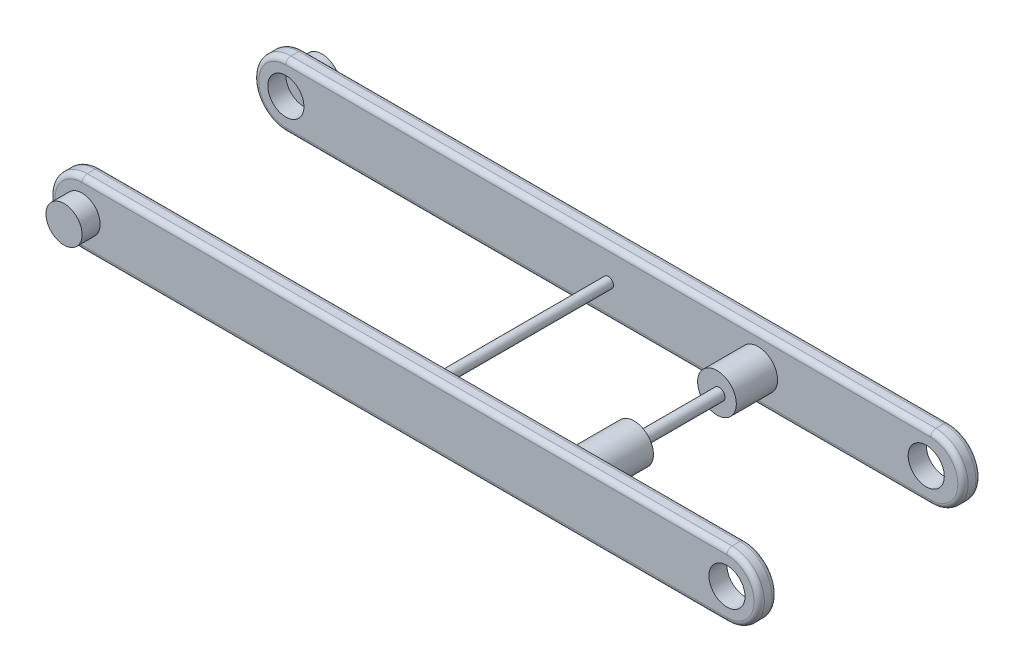
from build123d import *

# Parameters (mm, degrees)
BOSS_EXTRUDE1_DEPTH = 7
SKETCH2_R           = 7
CUT_EXTRUDE1_DEPTH  = 7
SKETCH3_R           = 7
CUT_EXTRUDE2_DEPTH  = 7
BOSS_EXTRUDE2_DEPTH = 7
SKETCH5_R           = 7
CUT_EXTRUDE3_DEPTH  = 7
SKETCH6_R           = 7
BOSS_EXTRUDE3_DEPTH = 7
SKETCH8_R           = 7.21207686
BOSS_EXTRUDE4_DEPTH = 7
FILLET1_R           = 2
FILLET2_R           = 2
SKETCH9_R           = 2
BOSS_EXTRUDE5_DEPTH = 82
SKETCH10_R          = 2.25
BOSS_EXTRUDE6_DEPTH = 82
SKETCH11_R          = 7.5
BOSS_EXTRUDE7_DEPTH = 23
SKETCH12_R          = 7.5
BOSS_EXTRUDE8_DEPTH = 23


with BuildPart() as part:
    # Sketch1 → Boss-Extrude1 (new body)
    with BuildSketch(Plane.XY):
        with BuildLine():
            Line((-125, 12.5), (125, 12.5))
            ThreePointArc((125, 12.5), (137.5, 0), (125, -12.5))
            Line((125, -12.5), (-125, -12.5))
            ThreePointArc((-125, -12.5), (-137.5, 0), (-125, 12.5))
        make_face()
    extrude(amount=BOSS_EXTRUDE1_DEPTH)

    # Sketch2 → Cut-Extrude1 (cut)
    with BuildSketch(Plane.XY.offset(7)):
        with Locations((-125, 0)):
            Circle(SKETCH2_R)
    extrude(amount=-CUT_EXTRUDE1_DEPTH, mode=Mode.SUBTRACT)

    # Sketch3 → Cut-Extrude2 (cut)
    with BuildSketch(Plane.XY.offset(7)):
        with Locations((123.250988895, 0)):
            Circle(SKETCH3_R)
    extrude(amount=-CUT_EXTRUDE2_DEPTH, mode=Mode.SUBTRACT)

    # Sketch8 → Boss-Extrude4 (add)
    with BuildSketch(Plane(origin=(0, 0, 0), x_dir=(-1, 0, 0), z_dir=(0, 0, -1))):
        with Locations((125, 0)):
            Circle(SKETCH8_R)
    extrude(amount=BOSS_EXTRUDE4_DEPTH)

    # Fillet2
    fillet2_edges = [part.edges().sort_by_distance(p)[0] for p in [
        (137.5, 0, 7),
        (0, 12.5, 7),
        (-137.5, 0, 7),
        (0, 12.5, 0),
        (137.5, 0, 0),
        (0, -12.5, 0),
        (-137.5, 0, 0),
        (0, -12.5, 7),
    ]]
    fillet(fillet2_edges, radius=FILLET2_R)



with BuildPart() as body_2:
    # Sketch4 → Boss-Extrude2 (new body)
    with BuildSketch(Plane.XY.offset(79)):
        with BuildLine():
            Line((125, -12.5), (-125, -12.5))
            ThreePointArc((-125, -12.5), (-137.5, 0), (-125, 12.5))
            Line((-125, 12.5), (125, 12.5))
            ThreePointArc((125, 12.5), (137.5, 0), (125, -12.5))
        make_face()
    extrude(amount=BOSS_EXTRUDE2_DEPTH)

    # Sketch5 → Cut-Extrude3 (cut)
    with BuildSketch(Plane.XY.offset(86)):
        with Locations((125, 0)):
            Circle(SKETCH5_R)
        with Locations((-125, 0)):
            Circle(SKETCH5_R)
    extrude(amount=-CUT_EXTRUDE3_DEPTH, mode=Mode.SUBTRACT)

    # Fillet1
    fillet1_edges = [body_2.edges().sort_by_distance(p)[0] for p in [
        (-137.5, 0, 86),
        (0, -12.5, 86),
        (137.5, 0, 86),
        (0, -12.5, 79),
        (-137.5, 0, 79),
        (0, 12.5, 79),
        (137.5, 0, 79),
        (0, 12.5, 86),
    ]]
    fillet(fillet1_edges, radius=FILLET1_R)


with BuildPart() as body_3:
    # Sketch6 → Boss-Extrude3 (new body)
    with BuildSketch(Plane.XY.offset(86)):
        with Locations((-125, 0)):
            Circle(SKETCH6_R)
    extrude(amount=BOSS_EXTRUDE3_DEPTH)


with BuildPart() as part_1:
    add(part.part)

    add(body_2.part)  # Boss-Extrude5 merges body 2
    # Sketch9 → Boss-Extrude5 (add)
    with BuildSketch(Plane(origin=(0, 0, 0), x_dir=(-1, 0, 0), z_dir=(0, 0, -1))):
        Circle(SKETCH9_R)
    extrude(amount=-BOSS_EXTRUDE5_DEPTH)

    # Sketch10 → Boss-Extrude6 (add)
    with BuildSketch(Plane(origin=(0, 0, 0), x_dir=(-1, 0, 0), z_dir=(0, 0, -1))):
        with Locations((-59, 0)):
            Circle(SKETCH10_R)
    extrude(amount=-BOSS_EXTRUDE6_DEPTH)

    # Sketch11 → Boss-Extrude7 (add)
    with BuildSketch(Plane(origin=(0, 0, 0), x_dir=(-1, 0, 0), z_dir=(0, 0, -1))):
        with Locations((-58.125494447, 0)):
            Circle(SKETCH11_R)
    extrude(amount=-BOSS_EXTRUDE7_DEPTH)

    # Sketch12 → Boss-Extrude8 (add)
    with BuildSketch(Plane(origin=(0, 0, 79), x_dir=(-1, 0, 0), z_dir=(0, 0, -1))):
        with Locations((-59, 0)):
            Circle(SKETCH12_R)
    extrude(amount=BOSS_EXTRUDE8_DEPTH)


solid = Compound([body_3.part, part_1.part])
